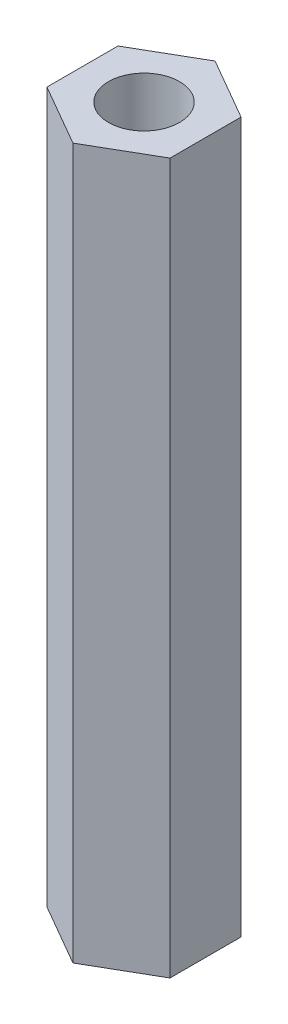
from build123d import *

# Parameters (mm, degrees)
SKETCH1_R           = 1.5
BOSS_EXTRUDE2_DEPTH = 30


with BuildPart() as part:
    # Sketch1 → Boss-Extrude2 (new body)
    with BuildSketch(Plane(origin=(0, 0, 0), x_dir=(1, 0, 0), z_dir=(0, 1, 0))):
        Polygon((0, 3.0022214), (-2.6, 1.5011107), (-2.6, -1.5011107), (0, -3.0022214), (2.6, -1.5011107), (2.6, 1.5011107), align=None)
        Circle(SKETCH1_R, mode=Mode.SUBTRACT)
    extrude(amount=BOSS_EXTRUDE2_DEPTH)


solid = part.part
